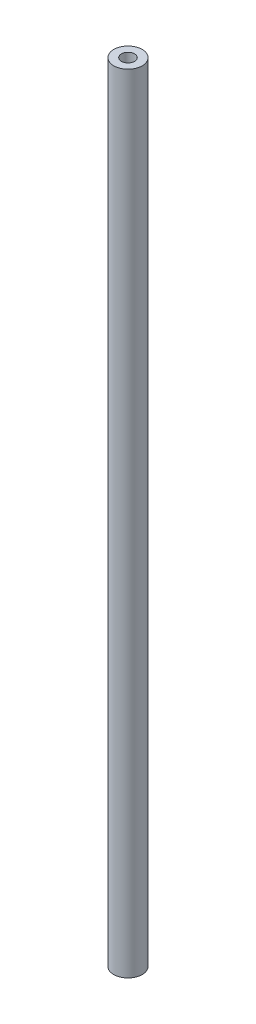
from build123d import *

# Parameters (mm, degrees)
SKETCH1_R           = 1.95
BOSS_EXTRUDE1_DEPTH = 108
SKETCH2_R           = 0.9
CUT_EXTRUDE1_DEPTH  = 112


with BuildPart() as part:
    # Sketch1 → Boss-Extrude1 (new body)
    with BuildSketch(Plane(origin=(0, 0, 0), x_dir=(1, 0, 0), z_dir=(0, 1, 0))):
        Circle(SKETCH1_R)
    extrude(amount=BOSS_EXTRUDE1_DEPTH)

    # Sketch2 → Cut-Extrude1 (cut)
    with BuildSketch(Plane(origin=(0, 108, 0), x_dir=(1, 0, 0), z_dir=(0, 1, 0))):
        Circle(SKETCH2_R)
    extrude(amount=-CUT_EXTRUDE1_DEPTH, mode=Mode.SUBTRACT)


solid = part.part
